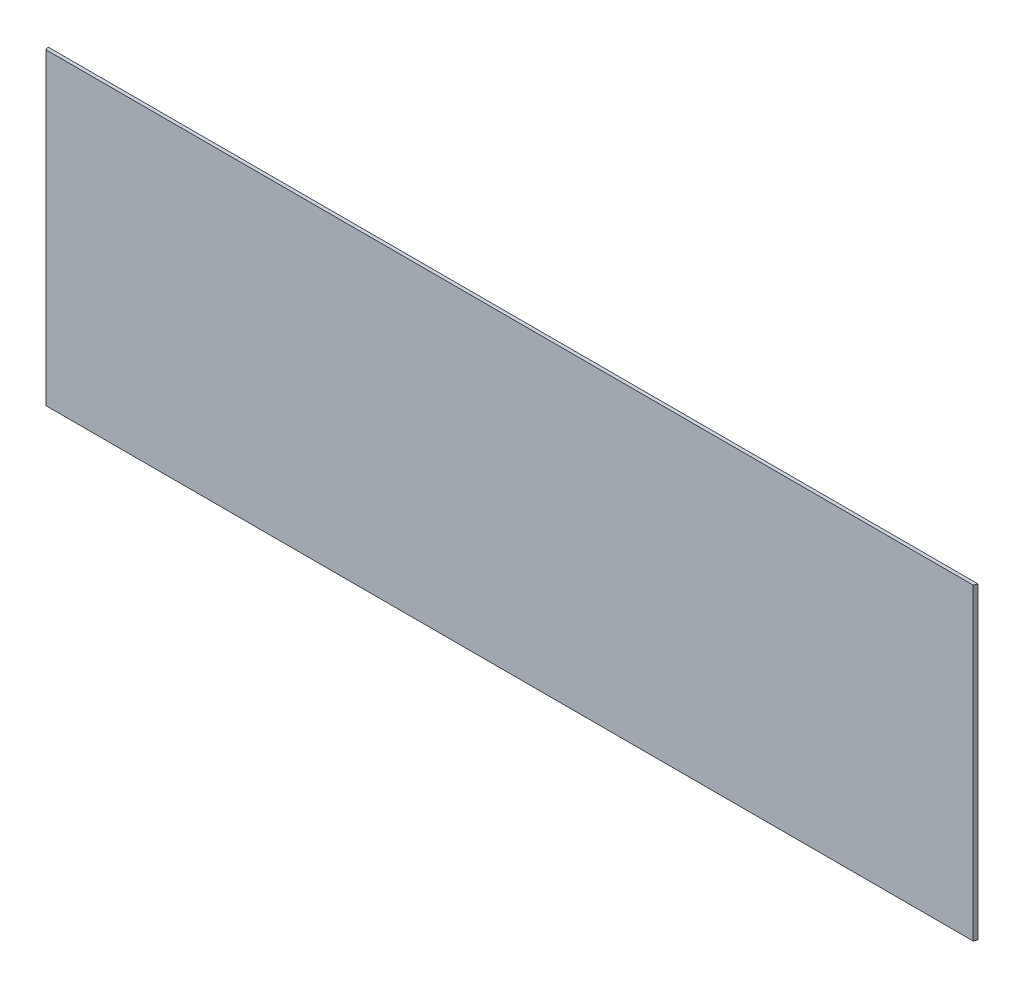
from build123d import *

# Parameters (mm, degrees)
EXTRUDE1_DEPTH = 142.875


with BuildPart() as part:
    # Sketch1 → Extrude1 (new body, symmetric)
    with BuildSketch(Plane(origin=(0, 0, 0), x_dir=(1, 0, 0), z_dir=(0, 1, 0))):
        Polygon((431.038, 1.5875), (429.722871939, -1.5875), (-429.722871939, -1.5875), (-431.038, 1.5875), align=None)
    extrude(amount=EXTRUDE1_DEPTH, both=True)


solid = part.part
